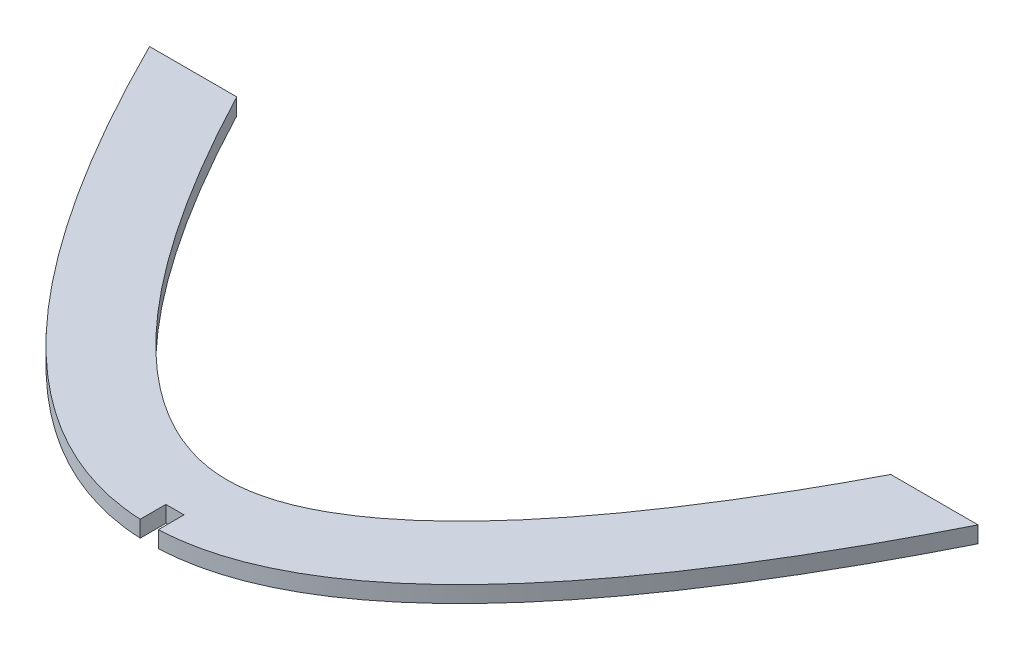
from build123d import *

# Parameters (mm, degrees)
BOSS_EXTRUDE2_DEPTH = 3.175
SKETCH2_W           = 3.5
SKETCH2_H           = 5
CUT_EXTRUDE1_DEPTH  = 114.181630536


with BuildPart() as part:
    # Sketch1 → Boss-Extrude2 (new body)
    with BuildSketch(Plane(origin=(0, 0, 0), x_dir=(1, 0, 0), z_dir=(0, 1, 0))):
        with BuildLine():
            add(Edge.make_bspline(
                [(-63.153287392, 80.000005207), (-62.690087061, 79.114787151), (-61.425361806, 76.720578148), (-59.365002639, 72.921941484), (-56.178071622, 67.245371862), (-52.217635229, 60.563206955), (-47.510051679, 53.209135647), (-42.857631564, 46.523268117), (-36.745022116, 38.503236865), (-29.311161013, 30.160913336), (-20.883951302, 22.824255391), (-13.153033777, 18.042065099), (-6.254689992, 15.505931404), (0, 14.747034298), (6.254689993, 15.505931404), (13.153033778, 18.042065099), (20.883951303, 22.824255391), (29.311161014, 30.160913336), (36.745022116, 38.503236864), (42.857631564, 46.523268116), (47.510051679, 53.209135647), (52.217635229, 60.563206955), (56.178071622, 67.245371862), (59.365002639, 72.921941484), (61.425361806, 76.720578148), (62.690087062, 79.114787152), (63.153287392, 80.000005207)],
                knots=[0.075765822, 0.075765822, 0.075765822, 0.075765822, 0.083776621, 0.097650734, 0.111524847, 0.139273072, 0.167021297, 0.194769522, 0.222517748, 0.278014198, 0.333510649, 0.389007099, 0.44450355, 0.5, 0.55549645, 0.610992901, 0.666489351, 0.721985802, 0.777482252, 0.805230478, 0.832978703, 0.860726928, 0.888475153, 0.902349266, 0.916223379, 0.924234178, 0.924234178, 0.924234178, 0.924234178], degree=3))
            Line((63.153287392, 80.000005207), (80, 80))
            add(Edge.make_bspline(
                [(-80, 80), (0, -80), (80, 80)],
                knots=[0.056028396, 0.056028396, 0.056028396, 0.943971604, 0.943971604, 0.943971604], degree=2))
            Line((-80, 80), (-63.153287392, 80.000005207))
        make_face()
    extrude(amount=BOSS_EXTRUDE2_DEPTH)

    # Sketch2 → Cut-Extrude1 (cut, through all)
    with BuildSketch(Plane(origin=(0, 3.175, 0), x_dir=(1, 0, 0), z_dir=(0, 1, 0))):
        with Locations((-0.08811954, 2.5)):
            Rectangle(SKETCH2_W, SKETCH2_H)
    extrude(amount=-CUT_EXTRUDE1_DEPTH, mode=Mode.SUBTRACT)


solid = part.part
